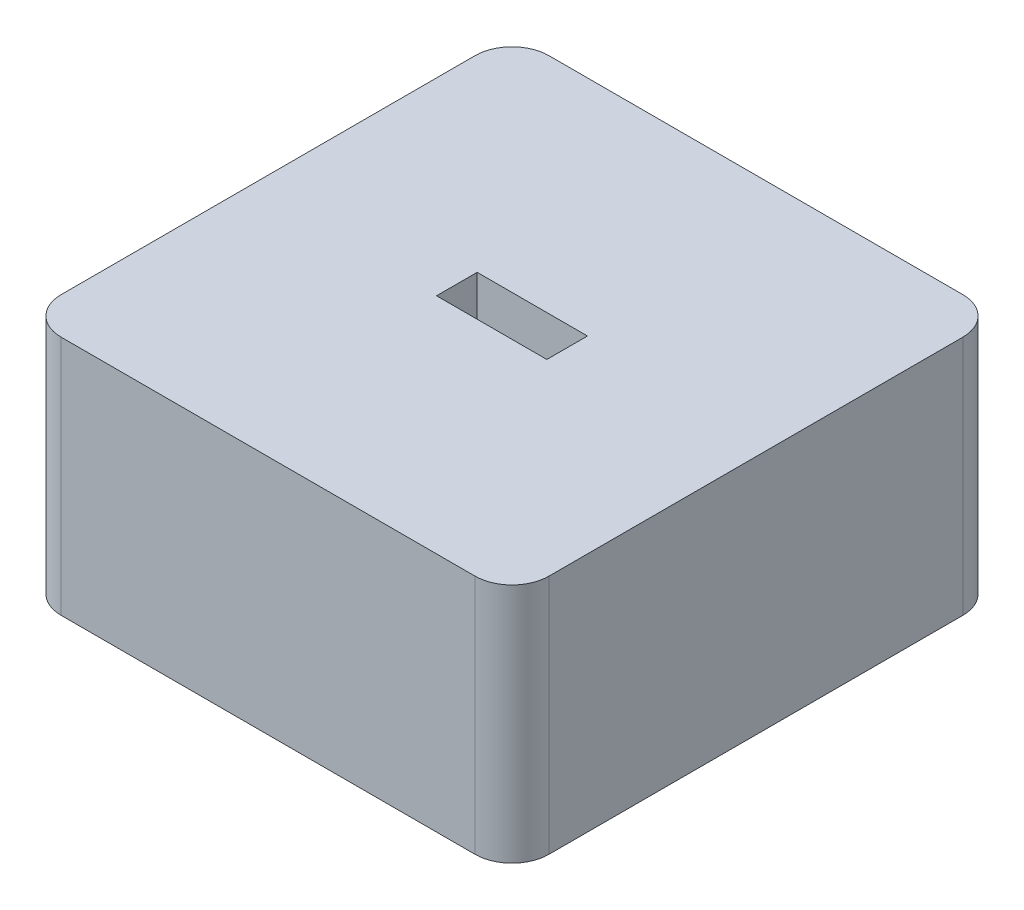
from build123d import *

# Parameters (mm, degrees)
SKETCH1_W           = 42
SKETCH1_H           = 42
BOSS_EXTRUDE1_DEPTH = 20.75
SKETCH2_W           = 9.5
SKETCH2_H           = 3.5
CUT_EXTRUDE4_DEPTH  = 3.52
SKETCH3_W           = 15.5
SKETCH3_H           = 10.5
CUT_EXTRUDE1_DEPTH  = 15.23
CUT_EXTRUDE2_REACH  = 19.23
SKETCH5_W           = 34
SKETCH5_H           = 34
SKETCH5_W_2         = 21.5
SKETCH5_H_2         = 16.5
CUT_EXTRUDE5_DEPTH  = 10
FILLET1_R           = 3.175


with BuildPart() as part:
    # Sketch1 → Boss-Extrude1 (new body)
    with BuildSketch(Plane(origin=(0, 0, 0), x_dir=(1, 0, 0), z_dir=(0, 1, 0))):
        with Locations((21, 21)):
            Rectangle(SKETCH1_W, SKETCH1_H)
    extrude(amount=BOSS_EXTRUDE1_DEPTH)

    # Sketch2 → Cut-Extrude4 (cut)
    with BuildSketch(Plane(origin=(0, 20.75, 0), x_dir=(1, 0, 0), z_dir=(0, 1, 0))):
        with Locations((21, 21)):
            Rectangle(SKETCH2_W, SKETCH2_H)
    extrude(amount=-CUT_EXTRUDE4_DEPTH, mode=Mode.SUBTRACT)

    # Sketch3 → Cut-Extrude1 (cut)
    with BuildSketch(Plane.XZ):
        with Locations((21, -21)):
            Rectangle(SKETCH3_W, SKETCH3_H)
    extrude(amount=-CUT_EXTRUDE1_DEPTH, mode=Mode.SUBTRACT)

    # Sketch4 → Cut-Extrude2 (cut, up to next)
    with BuildSketch(Plane(origin=(0, 17.23, 0), x_dir=(1, 0, 0), z_dir=(0, 1, 0)), mode=Mode.PRIVATE) as cut_extrude2_sk1:
        with BuildLine():
            Line((17.975, 22.275), (24.025, 22.275))
            ThreePointArc((24.025, 22.275), (25.3, 21), (24.025, 19.725))
            Line((24.025, 19.725), (17.975, 19.725))
            ThreePointArc((17.975, 19.725), (16.7, 21), (17.975, 22.275))
        make_face()
    cut_extrude2_tool1 = extrude(cut_extrude2_sk1.sketch, amount=-CUT_EXTRUDE2_REACH, mode=Mode.PRIVATE) & part.part
    add(cut_extrude2_tool1.solids().sort_by_distance((21, 17.23, -21))[0], mode=Mode.SUBTRACT)

    # Sketch5 → Cut-Extrude5 (cut)
    with BuildSketch(Plane.XZ):
        with Locations((21, -21)):
            Rectangle(SKETCH5_W, SKETCH5_H)
        with Locations((21, -21)):
            Rectangle(SKETCH5_W_2, SKETCH5_H_2, mode=Mode.SUBTRACT)
    extrude(amount=-CUT_EXTRUDE5_DEPTH, mode=Mode.SUBTRACT)

    # Fillet1
    fillet1_edges = [part.edges().sort_by_distance(p)[0] for p in [
        (0, 10.375, -42),
        (42, 10.375, -42),
        (42, 10.375, 0),
        (0, 10.375, 0),
    ]]
    fillet(fillet1_edges, radius=FILLET1_R)


solid = part.part
